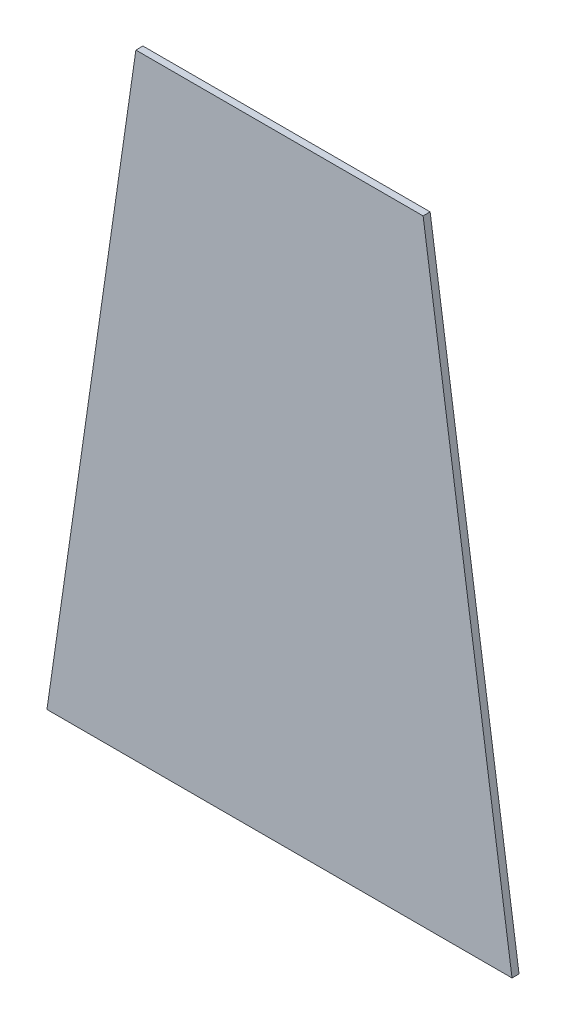
from build123d import *

# Parameters (mm, degrees)
SKETCH1_W           = 133.35
SKETCH1_H           = 285.75
BOSS_EXTRUDE1_DEPTH = 3.2639


with BuildPart() as part:
    # Sketch1 → Boss-Extrude1 (new body)
    with BuildSketch(Plane.XY):
        Polygon((-66.675, 142.875), (-107.95, -142.875), (-66.675, -142.875), align=None)
        Rectangle(SKETCH1_W, SKETCH1_H)
        Polygon((66.675, -142.875), (107.95, -142.875), (66.675, 142.875), align=None)
    extrude(amount=BOSS_EXTRUDE1_DEPTH)


solid = part.part
